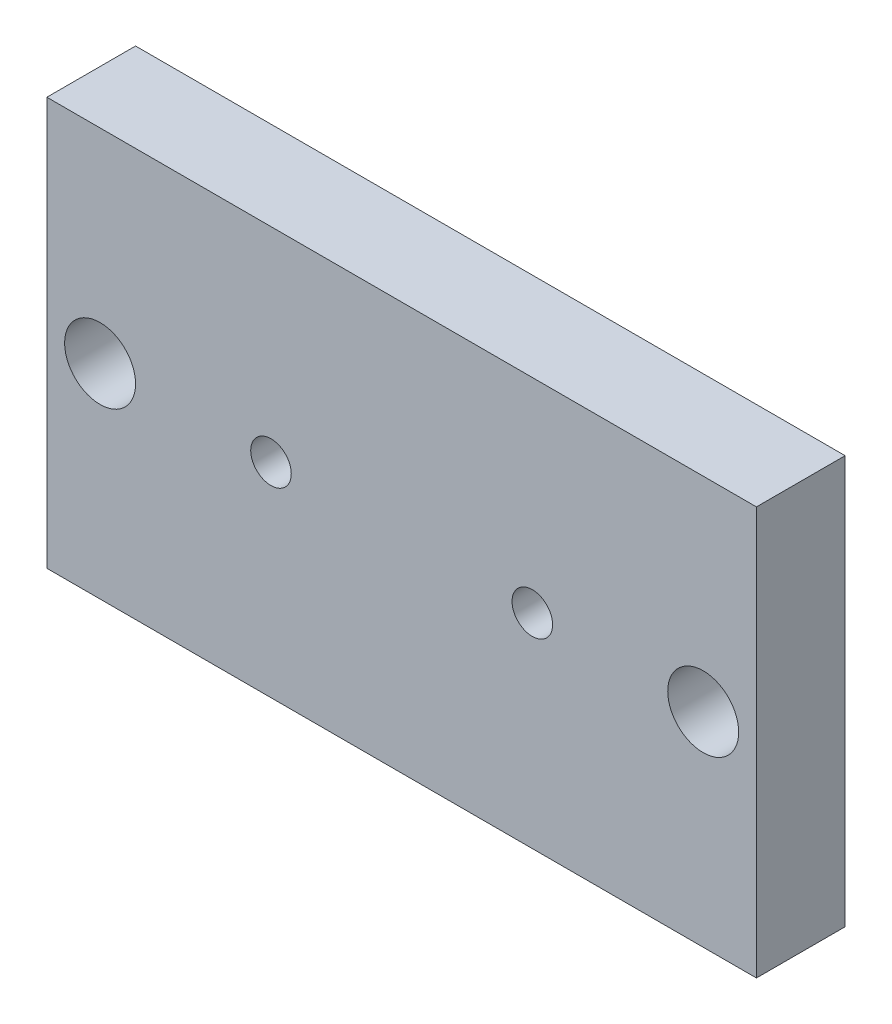
from build123d import *

# Parameters (mm, degrees)
SKETCH1_W           = 40
SKETCH1_H           = 23
BOSS_EXTRUDE1_DEPTH = 5
SKETCH2_R           = 2
SKETCH2_R_2         = 1.143
CUT_EXTRUDE1_DEPTH  = 10


with BuildPart() as part:
    # Sketch1 → Boss-Extrude1 (new body)
    with BuildSketch(Plane.XY):
        Rectangle(SKETCH1_W, SKETCH1_H)
    extrude(amount=BOSS_EXTRUDE1_DEPTH)

    # Sketch2 → Cut-Extrude1 (cut)
    with BuildSketch(Plane(origin=(0, 0, 0), x_dir=(-1, 0, 0), z_dir=(0, 0, -1))):
        with Locations((-17, 0)):
            Circle(SKETCH2_R)
        with Locations((-7.366, 0)):
            Circle(SKETCH2_R_2)
        with Locations((7.366, 0)):
            Circle(SKETCH2_R_2)
        with Locations((17, 0)):
            Circle(SKETCH2_R)
    extrude(amount=-CUT_EXTRUDE1_DEPTH, mode=Mode.SUBTRACT)


solid = part.part
